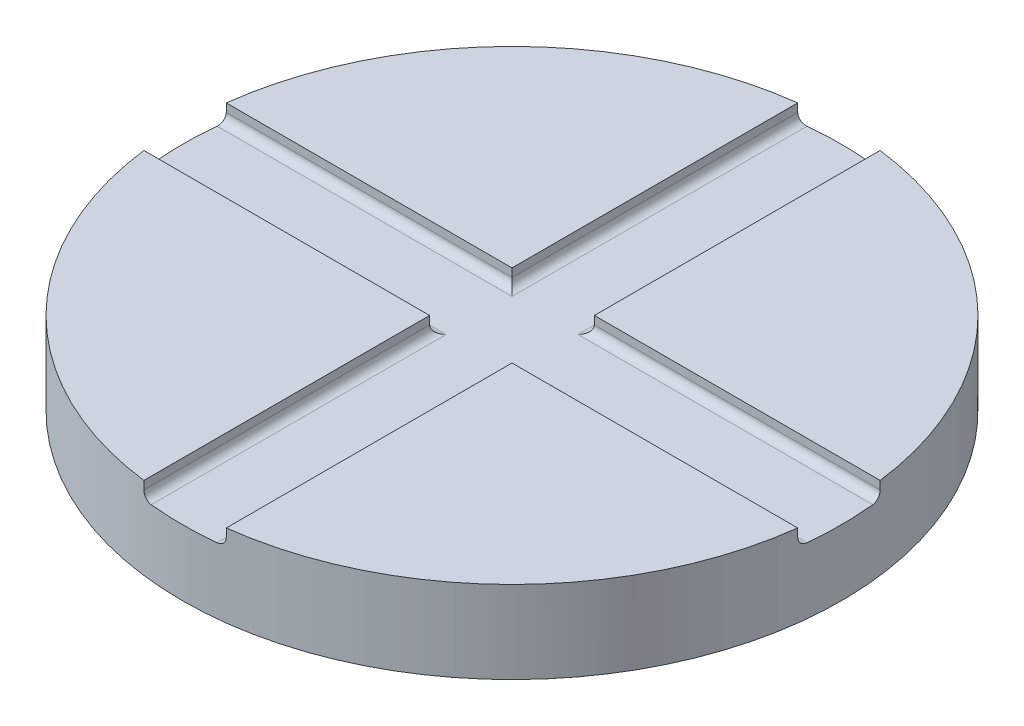
from build123d import *

# Parameters (mm, degrees)
SKETCH1_R           = 40
BOSS_EXTRUDE1_DEPTH = 10
CUT_EXTRUDE2_DEPTH  = 2
FILLET1_R           = 1


with BuildPart() as part:
    # Sketch1 → Boss-Extrude1 (new body)
    with BuildSketch(Plane(origin=(0, 0, 0), x_dir=(1, 0, 0), z_dir=(0, 1, 0))):
        Circle(SKETCH1_R)
    extrude(amount=BOSS_EXTRUDE1_DEPTH)

    # Sketch7 → Cut-Extrude2 (cut)
    with BuildSketch(Plane(origin=(0, 10, 0), x_dir=(1, 0, 0), z_dir=(0, 1, 0))):
        with BuildLine():
            Line((-5, 39.686269666), (-5, 5))
            Line((-5, 5), (-39.686269666, 5))
            ThreePointArc((-39.686269666, 5), (-40, 0), (-39.686269666, -5))
            Line((-39.686269666, -5), (-5, -5))
            Line((-5, -5), (-5, -39.686269666))
            ThreePointArc((-5, -39.686269666), (0, -40), (5, -39.686269666))
            Line((5, -39.686269666), (5, -5))
            Line((5, -5), (39.686269666, -5))
            ThreePointArc((39.686269666, -5), (40, 0), (39.686269666, 5))
            Line((39.686269666, 5), (5, 5))
            Line((5, 5), (5, 39.686269666))
            ThreePointArc((5, 39.686269666), (0, 40), (-5, 39.686269666))
        make_face()
    extrude(amount=-CUT_EXTRUDE2_DEPTH, mode=Mode.SUBTRACT)

    # Fillet1
    fillet1_edges = [part.edges().sort_by_distance(p)[0] for p in [
        (5, 8, -22.343134833),
        (22.343134833, 8, -5),
        (22.343134833, 8, 5),
        (5, 8, 22.343134833),
        (-5, 8, 22.343134833),
        (-22.343134833, 8, 5),
        (-22.343134833, 8, -5),
        (-5, 8, -22.343134833),
    ]]
    fillet(fillet1_edges, radius=FILLET1_R)


solid = part.part
